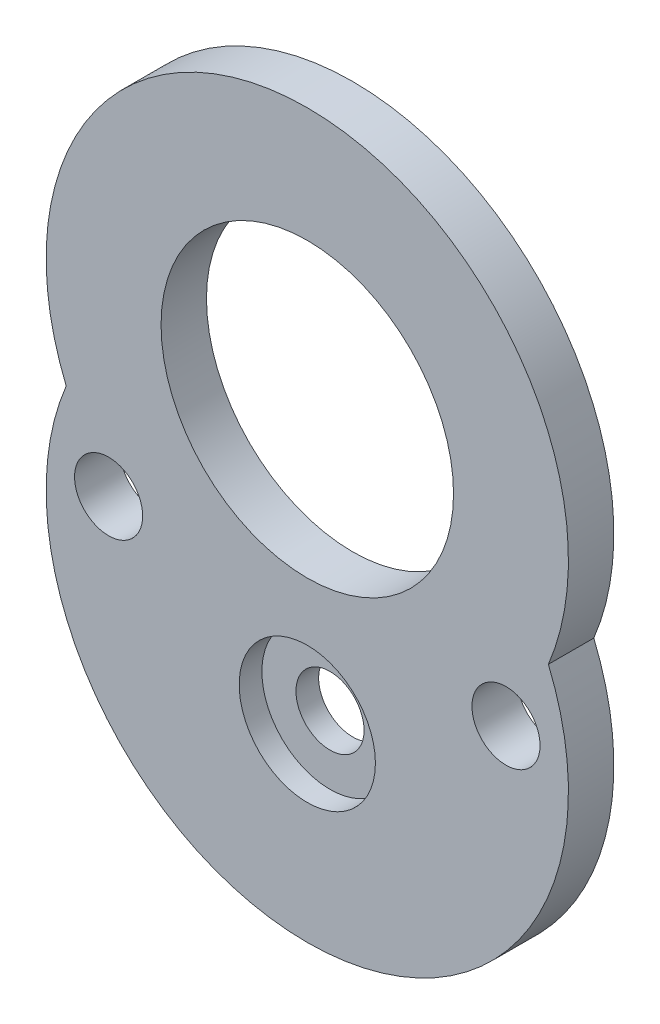
from build123d import *

# Parameters (mm, degrees)
SKETCH_1_W          = 24
SKETCH_1_H          = 33.932299882
SKETCH_1_R          = 1.5
SKETCH_1_R_2        = 6.44
SKETCH_1_R_3        = 3
EXTRUDE_1_DEPTH     = 2
CUT_EXTRUDE_START   = 2
SKETCH_1_3_R        = 3
SKETCH_1_3_R_2      = 1.5
CUT_EXTRUDE_1_DEPTH = 1
SKETCH_2_W          = 24
SKETCH_2_H          = 33.932299882
CUT_EXTRUDE_3_DEPTH = 3


with BuildPart() as part:
    # 草图1 → 凸台-拉伸1 (new body)
    with BuildSketch(Plane.XY):
        with Locations((0, -4.966149941)):
            Rectangle(SKETCH_1_W, SKETCH_1_H)
        with Locations((-8.75, -7.7)):
            Circle(SKETCH_1_R, mode=Mode.SUBTRACT)
        Circle(SKETCH_1_R_2, mode=Mode.SUBTRACT)
        with Locations((0, -12)):
            Circle(SKETCH_1_R_3, mode=Mode.SUBTRACT)
        with Locations((8.75, -7.7)):
            Circle(SKETCH_1_R, mode=Mode.SUBTRACT)
        with Locations((0, -12)):
            Circle(SKETCH_1_R_3)
        with Locations((0, -12)):
            Circle(SKETCH_1_R, mode=Mode.SUBTRACT)
    extrude(amount=EXTRUDE_1_DEPTH)

    # 草图1<3> → 切除-拉伸1 (cut)
    with BuildSketch(Plane.XY.offset(CUT_EXTRUDE_START)):
        with Locations((0, -12)):
            Circle(SKETCH_1_3_R)
        with Locations((0, -12)):
            Circle(SKETCH_1_3_R_2, mode=Mode.SUBTRACT)
    extrude(amount=-CUT_EXTRUDE_1_DEPTH, mode=Mode.SUBTRACT)

    # 草图2 → 切除-拉伸3 (cut, through all)
    with BuildSketch(Plane.XY.offset(2)):
        with Locations((0, -4.966149941)):
            Rectangle(SKETCH_2_W, SKETCH_2_H)
        with BuildLine():
            ThreePointArc((-10.616967552, -4.419275959), (0, -20.338551918), (10.616967552, -4.419275959))
            ThreePointArc((10.616967552, -4.419275959), (0, 11.5), (-10.616967552, -4.419275959))
        make_face(mode=Mode.SUBTRACT)
    extrude(amount=-CUT_EXTRUDE_3_DEPTH, mode=Mode.SUBTRACT)


solid = part.part
